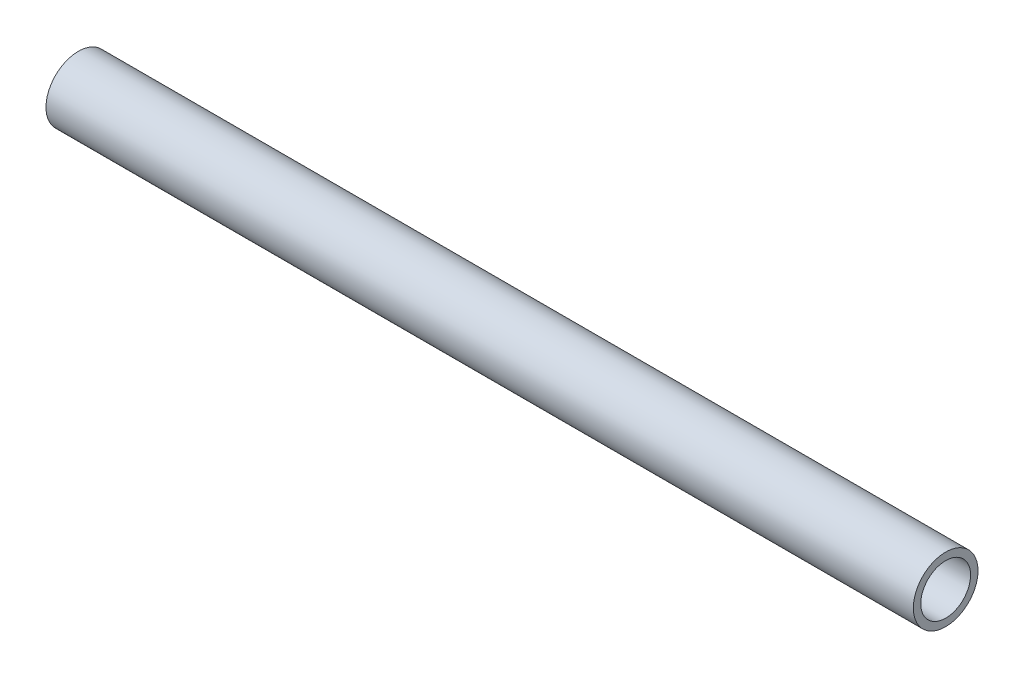
from build123d import *


with BuildPart() as part:
    # Sketch1 → Revolve1 (revolve)
    with BuildSketch(Plane.XY):
        Polygon((-140, 6.604), (-140, 8.5725), (89.8802, 8.5725), (89.8802, 6.604), (79.7202, 6.604), (79.7202, 6.2357), (-129.84, 6.2357), (-129.84, 6.604), align=None)
    revolve(axis=Axis((-110.229678616, 0, 0), (1, 0, 0)))


solid = part.part
